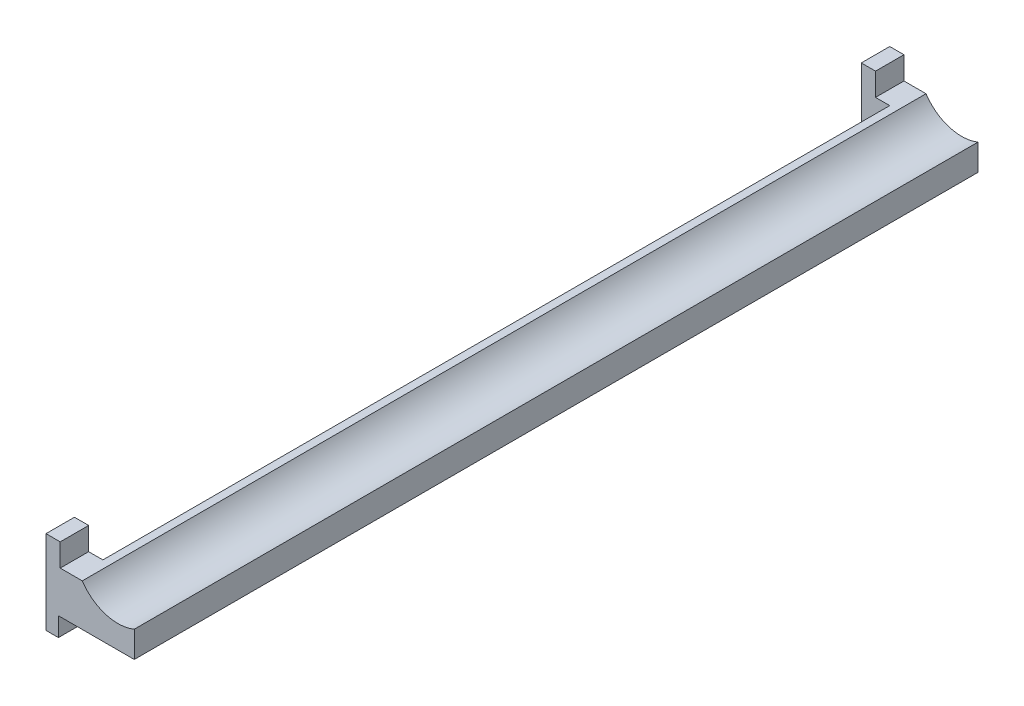
from build123d import *

# Parameters (mm, degrees)
BOSS_EXTRUDE1_DEPTH = 890
SKETCH2_W           = 830
SKETCH2_H           = 88.44
CUT_EXTRUDE1_DEPTH  = 30


with BuildPart() as part:
    # Sketch1 → Boss-Extrude1 (new body)
    with BuildSketch(Plane.XY):
        with BuildLine():
            Line((187.42, 44.22), (187.42, -44.22))
            Line((187.42, -44.22), (200.51881238, -44.22))
            Line((200.51881238, -44.22), (200.51881238, -24.22))
            Line((200.51881238, -24.22), (280.51881238, -24.22))
            Line((280.51881238, -24.22), (280.51881238, 3.445359838))
            ThreePointArc((280.51881238, 3.445359838), (250.085390083, 1.968696909), (225.68736431, 20.22))
            Line((225.68736431, 20.22), (202.42, 20.22))
            Line((202.42, 20.22), (202.42, 44.22))
            Line((202.42, 44.22), (187.42, 44.22))
        make_face()
    extrude(amount=-BOSS_EXTRUDE1_DEPTH)

    # Sketch2 → Cut-Extrude1 (cut)
    with BuildSketch(Plane.ZY.offset(-187.42)):
        with Locations((-445, 0)):
            Rectangle(SKETCH2_W, SKETCH2_H)
    extrude(amount=-CUT_EXTRUDE1_DEPTH, mode=Mode.SUBTRACT)


solid = part.part
